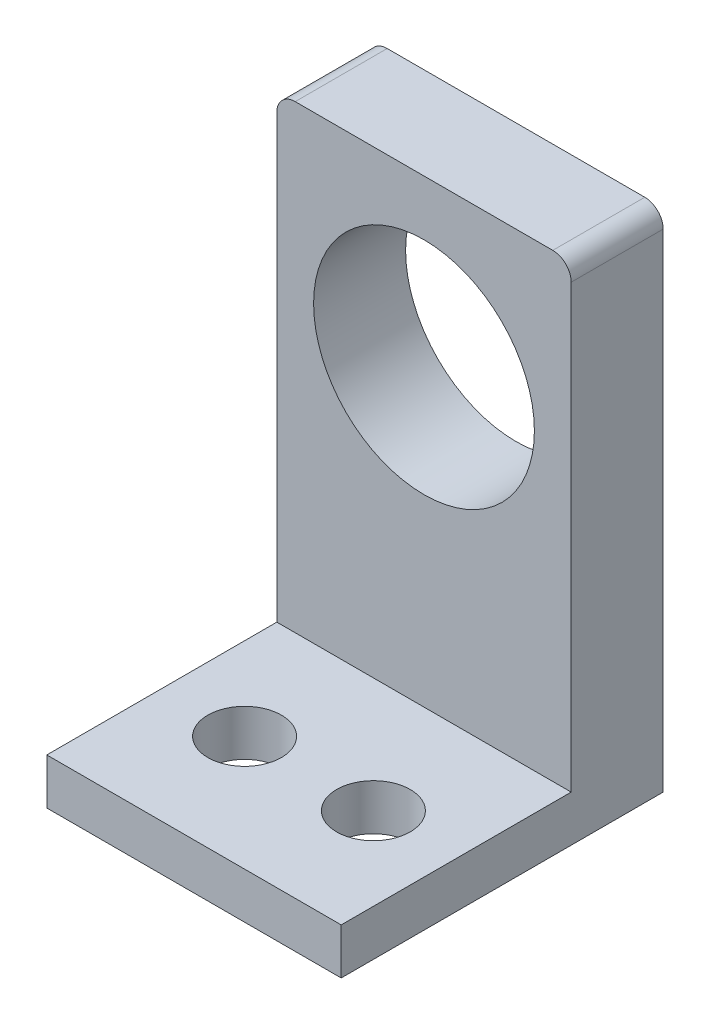
from build123d import *

# Parameters (mm, degrees)
SKETCH1_R           = 12
BOSS_EXTRUDE1_DEPTH = 10
SKETCH2_W           = 32
SKETCH2_H           = 5
BOSS_EXTRUDE2_DEPTH = 25
SKETCH3_R           = 4
CUT_EXTRUDE1_DEPTH  = 25


with BuildPart() as part:
    # Sketch1 → Boss-Extrude1 (new body)
    with BuildSketch(Plane.XY):
        with BuildLine():
            Line((-16, -27.5), (16, -27.5))
            Line((16, -27.5), (16, 25.5))
            ThreePointArc((16, 25.5), (15.414213562, 26.914213562), (14, 27.5))
            Line((14, 27.5), (-14, 27.5))
            ThreePointArc((-14, 27.5), (-15.414213562, 26.914213562), (-16, 25.5))
            Line((-16, 25.5), (-16, -27.5))
        make_face()
        with Locations((0, 9.5)):
            Circle(SKETCH1_R, mode=Mode.SUBTRACT)
    extrude(amount=BOSS_EXTRUDE1_DEPTH)

    # Sketch2 → Boss-Extrude2 (add)
    with BuildSketch(Plane.XY.offset(10)):
        with Locations((0, -25)):
            Rectangle(SKETCH2_W, SKETCH2_H)
    extrude(amount=BOSS_EXTRUDE2_DEPTH)

    # Sketch3 → Cut-Extrude1 (cut)
    with BuildSketch(Plane(origin=(0, -22.5, 0), x_dir=(1, 0, 0), z_dir=(0, 1, 0))):
        with Locations((-7, -22.5)):
            Circle(SKETCH3_R)
        with Locations((7, -22.5)):
            Circle(SKETCH3_R)
    extrude(amount=-CUT_EXTRUDE1_DEPTH, mode=Mode.SUBTRACT)


solid = part.part
